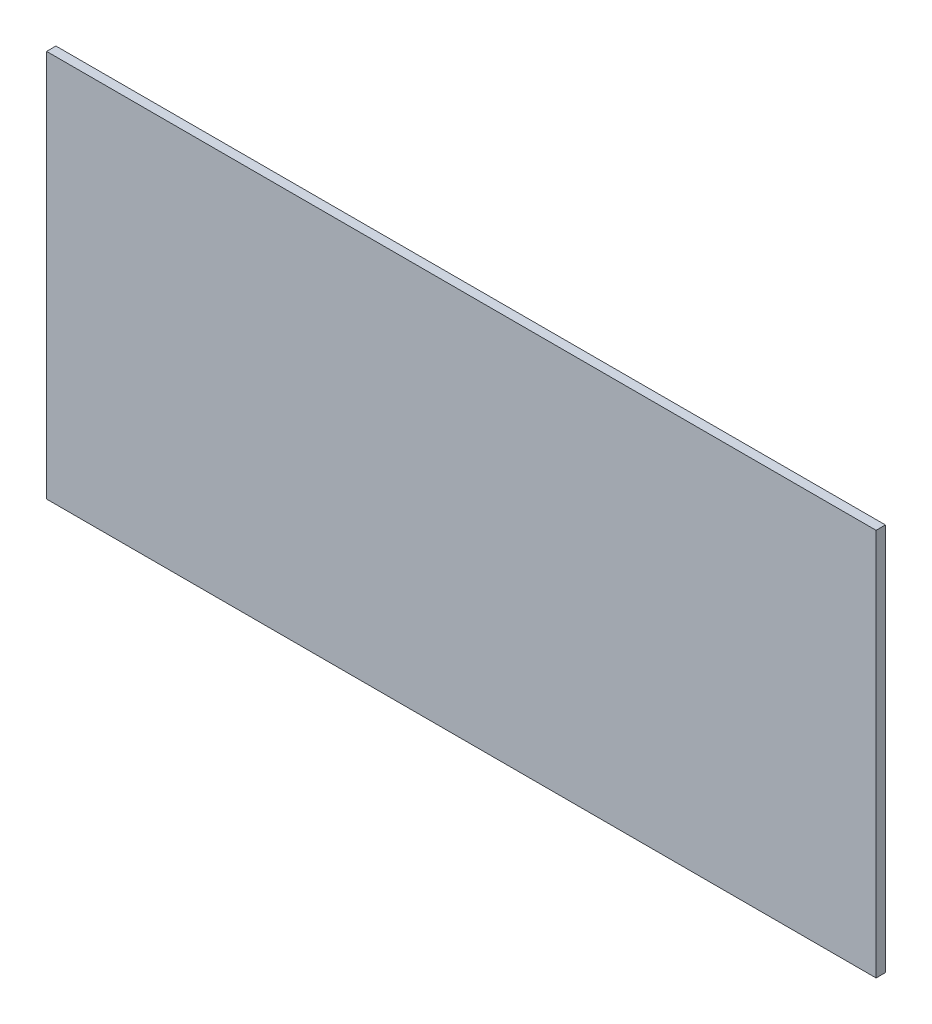
from build123d import *

# Parameters (mm, degrees)
SKETCH1_W           = 11.303
SKETCH1_H           = 5.2832
BOSS_EXTRUDE1_DEPTH = 0.127


with BuildPart() as part:
    # Sketch1 → Boss-Extrude1 (new body)
    with BuildSketch(Plane.XY):
        with Locations((36.193705076, 184.305520133)):
            Rectangle(SKETCH1_W, SKETCH1_H)
    extrude(amount=BOSS_EXTRUDE1_DEPTH)


solid = part.part
